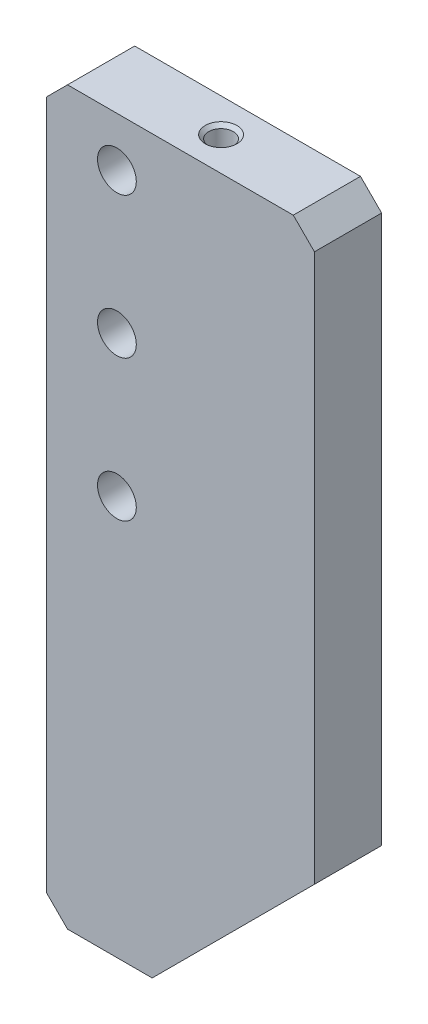
from build123d import *

# Parameters (mm, degrees)
BOSS_EXTRUDE1_DEPTH      = 4.7625
BOSS_EXTRUDE1_DEPTH_BACK = 4.7625
SKETCH1_R                = 2.75
CHAMFER1_SIZE            = 3
CHAMFER2_SIZE            = 0.5


with BuildPart() as part:
    # Sketch1 → Boss-Extrude1 (new, two sides: drawn at the far end of the back side and taken through both)
    with BuildSketch(Plane.XY.offset(-BOSS_EXTRUDE1_DEPTH_BACK)):
        Polygon((-170.247691321, 9.552308679), (-185.247691321, 9.552308679), (-185.247691321, 113.192388155), (-147.247691321, 113.192388155), (-147.247691321, 32.552308679), align=None)
        with Locations((-175.247691321, 66.192388155)):
            Circle(SKETCH1_R, mode=Mode.SUBTRACT)
        with Locations((-175.247691321, 86.192388155)):
            Circle(SKETCH1_R, mode=Mode.SUBTRACT)
        with Locations((-175.247691321, 106.192388155)):
            Circle(SKETCH1_R, mode=Mode.SUBTRACT)
    extrude(amount=BOSS_EXTRUDE1_DEPTH + BOSS_EXTRUDE1_DEPTH_BACK)

    # Sketch2 → Cut-Revolve1 (revolve, cut)
    with BuildSketch(Plane.XY):
        Polygon((-165.247691321, 113.192388155), (-166.997691321, 113.192388155), (-166.997691321, 108.192388155), (-166.447691321, 107.874845507), (-166.447691321, 93.019183075), (-165.247691321, 92.326362752), align=None)
    revolve(axis=Axis((-165.247691321, 113.192388155, 0), (0, -1, 0)), mode=Mode.SUBTRACT)

    # Chamfer1
    chamfer1_edges = [part.edges().sort_by_distance(p)[0] for p in [
        (-185.247691321, 9.552308679, 0),
        (-185.247691321, 113.192388155, 0),
        (-147.247691321, 113.192388155, 0),
    ]]
    chamfer(chamfer1_edges, length=CHAMFER1_SIZE)

    # Chamfer2
    chamfer2_edges = [part.edges().sort_by_distance(p)[0] for p in [
        (-163.497691321, 113.192388155, 0),
    ]]
    chamfer(chamfer2_edges, length=CHAMFER2_SIZE)


solid = part.part
